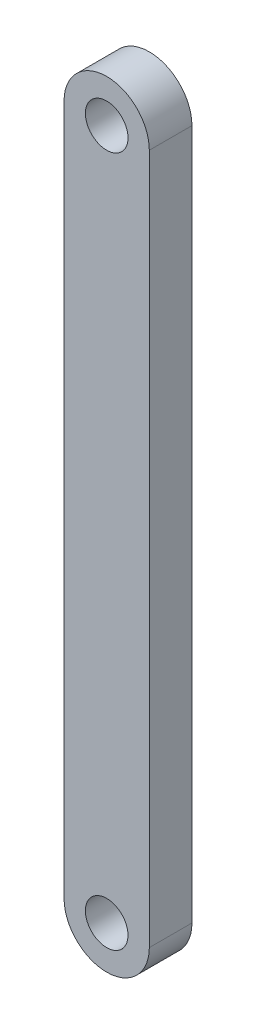
from build123d import *

# Parameters (mm, degrees)
SKETCH1_R           = 3.175
BOSS_EXTRUDE1_DEPTH = 6.35


with BuildPart() as part:
    # Sketch1 → Boss-Extrude1 (new body)
    with BuildSketch(Plane.XY):
        with BuildLine():
            Line((-6.35, 102.87), (-6.35, 0))
            ThreePointArc((-6.35, 0), (0, -6.35), (6.35, 0))
            Line((6.35, 0), (6.35, 102.87))
            ThreePointArc((6.35, 102.87), (0, 109.22), (-6.35, 102.87))
        make_face()
        with Locations((0, 102.87)):
            Circle(SKETCH1_R, mode=Mode.SUBTRACT)
        Circle(SKETCH1_R, mode=Mode.SUBTRACT)
    extrude(amount=BOSS_EXTRUDE1_DEPTH)


solid = part.part
